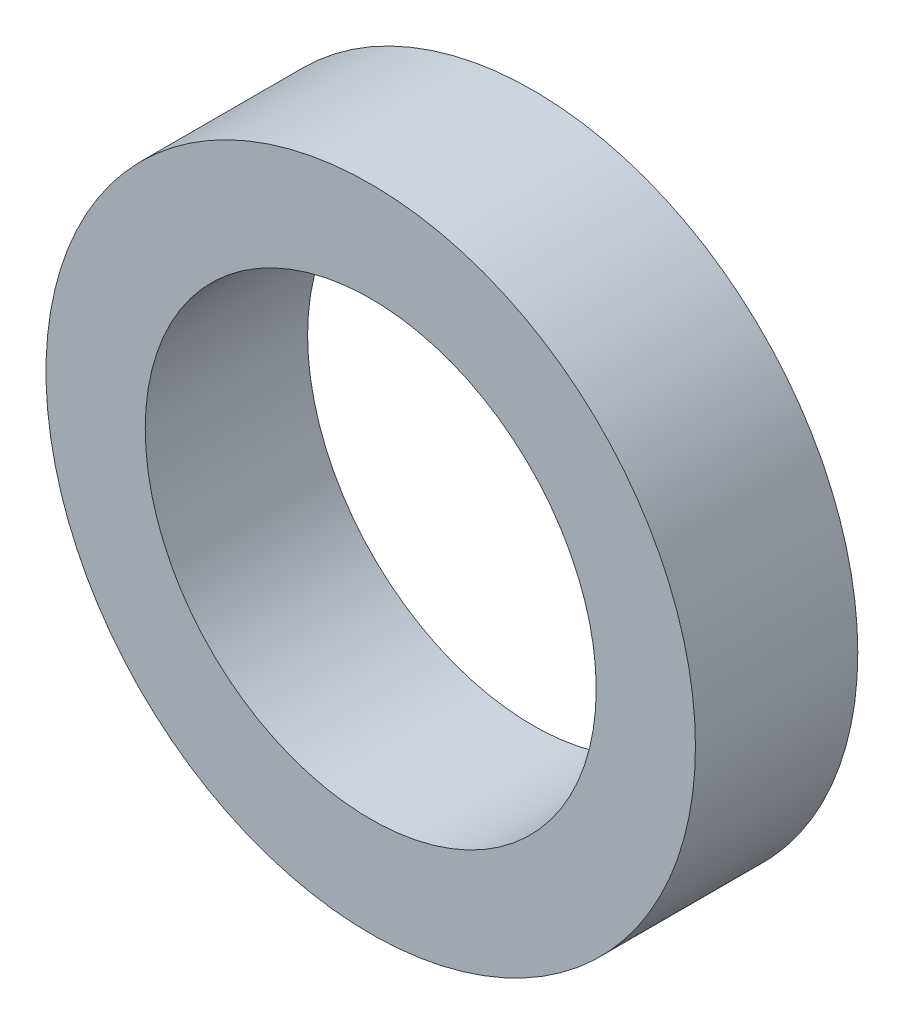
from build123d import *

# Parameters (mm, degrees)
SKETCH_1_R      = 9
SKETCH_1_R_2    = 6.25
EXTRUDE_1_DEPTH = 4.5


with BuildPart() as part:
    # 草图1 → 凸台-拉伸1 (new body)
    with BuildSketch(Plane.XY):
        Circle(SKETCH_1_R)
        Circle(SKETCH_1_R_2, mode=Mode.SUBTRACT)
    extrude(amount=EXTRUDE_1_DEPTH)


solid = part.part
